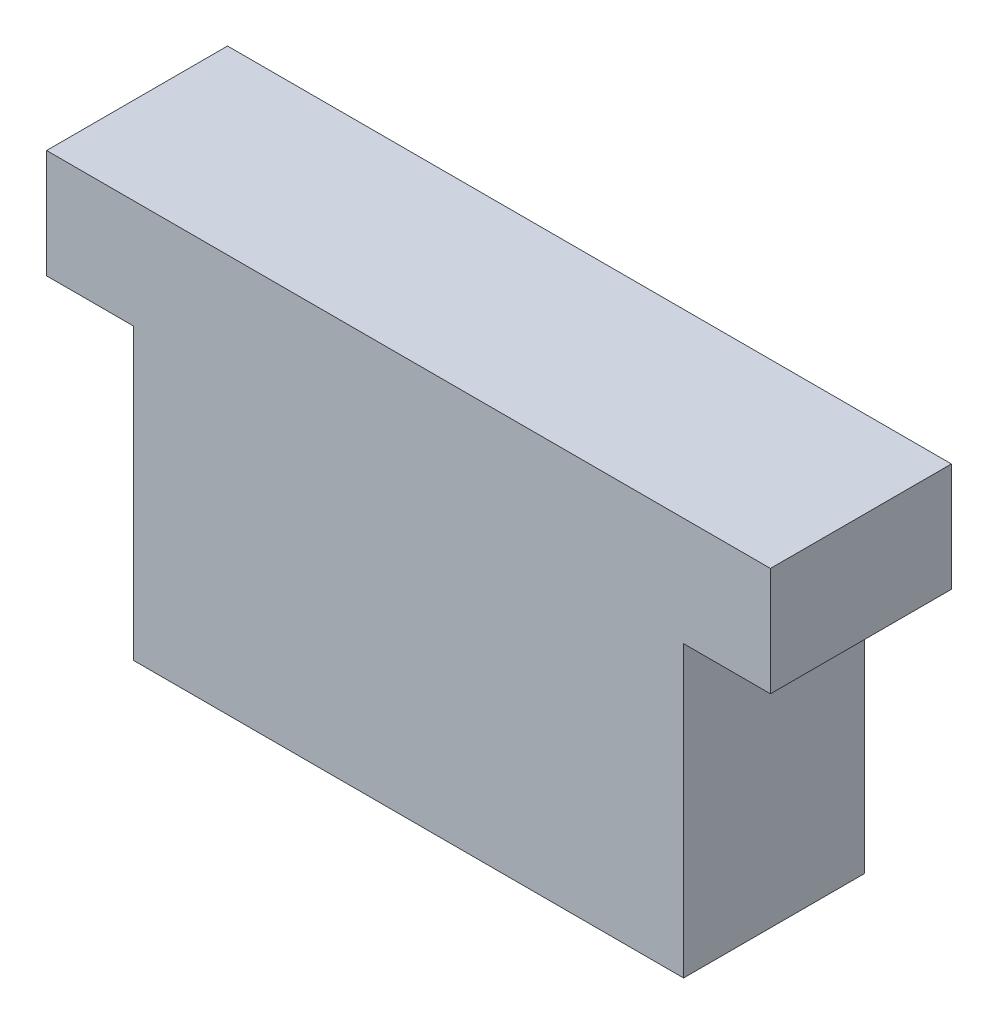
from build123d import *

# Parameters (mm, degrees)
SKETCH_1_W      = 20
SKETCH_1_H      = 3
SKETCH_1_W_2    = 15.2
SKETCH_1_H_2    = 8
EXTRUDE_1_DEPTH = 5


with BuildPart() as part:
    # 草图1 → 凸台-拉伸1 (new body)
    with BuildSketch(Plane.XY):
        Rectangle(SKETCH_1_W, SKETCH_1_H)
        with Locations((0, -5.5)):
            Rectangle(SKETCH_1_W_2, SKETCH_1_H_2)
    extrude(amount=EXTRUDE_1_DEPTH)


solid = part.part
